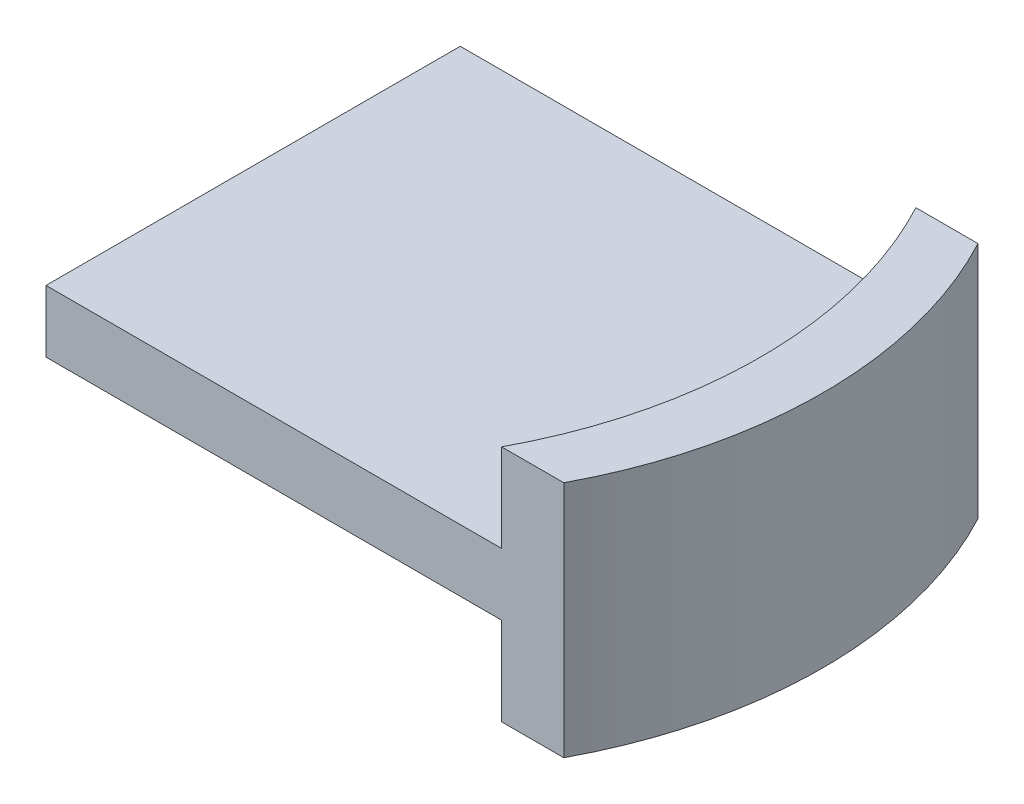
from build123d import *

# Parameters (mm, degrees)
BOSS_EXTRUDE1_DEPTH = 2.3
SKETCH3_W           = 10
SKETCH3_H           = 8
BOSS_EXTRUDE2_DEPTH = 0.6


with BuildPart() as part:
    # Sketch2 → Boss-Extrude1 (new body, symmetric)
    with BuildSketch(Plane(origin=(0, 0, 0), x_dir=(1, 0, 0), z_dir=(0, 1, 0))):
        with BuildLine():
            Line((0, 4), (1.2, 4))
            ThreePointArc((1.2, 4), (2.2, 0), (1.2, -4))
            Line((1.2, -4), (0, -4))
            ThreePointArc((0, -4), (1, 0), (0, 4))
        make_face()
    extrude(amount=BOSS_EXTRUDE1_DEPTH, both=True)

    # Sketch3 → Boss-Extrude2 (add, symmetric)
    with BuildSketch(Plane(origin=(0, 0, 0), x_dir=(1, 0, 0), z_dir=(0, 1, 0))):
        with Locations((-3.8, 0)):
            Rectangle(SKETCH3_W, SKETCH3_H)
    extrude(amount=BOSS_EXTRUDE2_DEPTH, both=True)


solid = part.part
